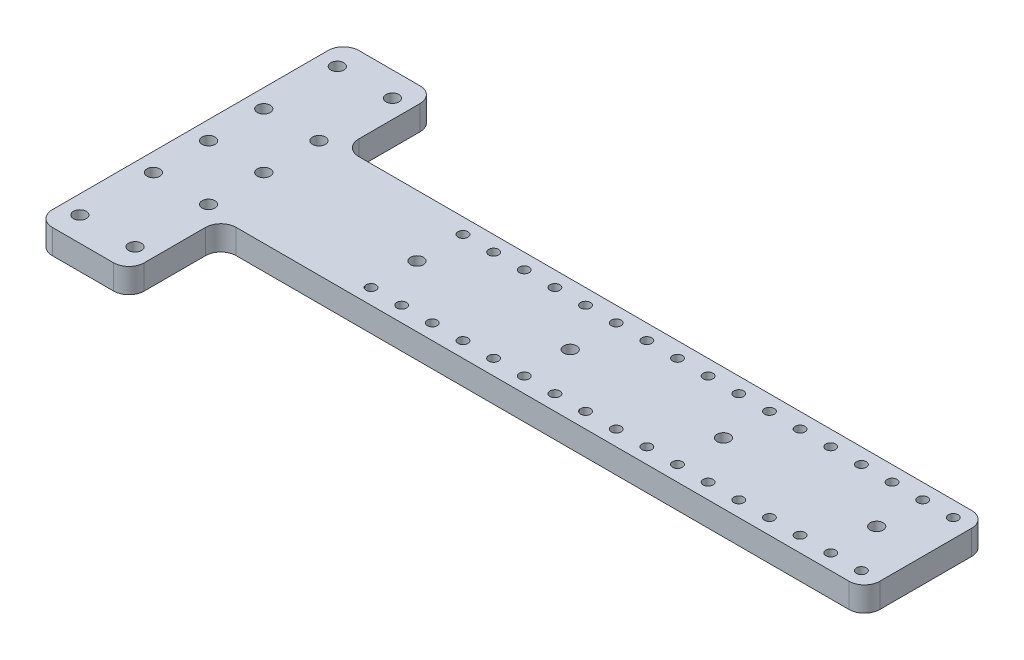
from build123d import *

# Parameters (mm, degrees)
SKETCH1_W           = 30
SKETCH1_H           = 100
SKETCH1_W_2         = 210
SKETCH1_H_2         = 40
BOSS_EXTRUDE1_DEPTH = 8
SKETCH3_R           = 2.1
CUT_EXTRUDE2_DEPTH  = 10
SKETCH2_R           = 2.1
CUT_EXTRUDE3_DEPTH  = 10
SKETCH4_R           = 1.6
CUT_EXTRUDE4_DEPTH  = 10
FILLET1_R           = 5


with BuildPart() as part:
    # Sketch1 → Boss-Extrude1 (new body)
    with BuildSketch(Plane(origin=(0, 0, 0), x_dir=(1, 0, 0), z_dir=(0, 1, 0))):
        Rectangle(SKETCH1_W, SKETCH1_H)
        with Locations((120, 0)):
            Rectangle(SKETCH1_W_2, SKETCH1_H_2)
    extrude(amount=BOSS_EXTRUDE1_DEPTH)

    # Sketch3 → Cut-Extrude2 (cut)
    with BuildSketch(Plane(origin=(0, 8, 0), x_dir=(1, 0, 0), z_dir=(0, 1, 0))):
        with Locations((-9, 0)):
            Circle(SKETCH3_R)
        with Locations((9, 0)):
            Circle(SKETCH3_R)
        with Locations((59, 0)):
            Circle(SKETCH3_R)
        with Locations((109, 0)):
            Circle(SKETCH3_R)
        with Locations((159, 0)):
            Circle(SKETCH3_R)
        with Locations((209, 0)):
            Circle(SKETCH3_R)
    extrude(amount=-CUT_EXTRUDE2_DEPTH, mode=Mode.SUBTRACT)

    # Sketch2 → Cut-Extrude3 (cut)
    with BuildSketch(Plane(origin=(0, 8, 0), x_dir=(1, 0, 0), z_dir=(0, 1, 0))):
        with Locations((-9, -42)):
            Circle(SKETCH2_R)
        with Locations((-9, -18)):
            Circle(SKETCH2_R)
        with Locations((9, -18)):
            Circle(SKETCH2_R)
        with Locations((9, -42)):
            Circle(SKETCH2_R)
        with Locations((9, 42)):
            Circle(SKETCH2_R)
        with Locations((9, 18)):
            Circle(SKETCH2_R)
        with Locations((-9, 18)):
            Circle(SKETCH2_R)
        with Locations((-9, 42)):
            Circle(SKETCH2_R)
    extrude(amount=-CUT_EXTRUDE3_DEPTH, mode=Mode.SUBTRACT)

    # Sketch4 → Cut-Extrude4 (cut)
    with BuildSketch(Plane(origin=(0, 8, 0), x_dir=(1, 0, 0), z_dir=(0, 1, 0))):
        with Locations((59, -15)):
            Circle(SKETCH4_R)
        with Locations((59, 15)):
            Circle(SKETCH4_R)
        with Locations((69, 15)):
            Circle(SKETCH4_R)
        with Locations((69, -15)):
            Circle(SKETCH4_R)
        with Locations((79, 15)):
            Circle(SKETCH4_R)
        with Locations((79, -15)):
            Circle(SKETCH4_R)
        with Locations((89, 15)):
            Circle(SKETCH4_R)
        with Locations((89, -15)):
            Circle(SKETCH4_R)
        with Locations((99, -15)):
            Circle(SKETCH4_R)
        with Locations((99, 15)):
            Circle(SKETCH4_R)
        with Locations((109, -15)):
            Circle(SKETCH4_R)
        with Locations((109, 15)):
            Circle(SKETCH4_R)
        with Locations((119, -15)):
            Circle(SKETCH4_R)
        with Locations((119, 15)):
            Circle(SKETCH4_R)
        with Locations((129, -15)):
            Circle(SKETCH4_R)
        with Locations((129, 15)):
            Circle(SKETCH4_R)
        with Locations((139, -15)):
            Circle(SKETCH4_R)
        with Locations((139, 15)):
            Circle(SKETCH4_R)
        with Locations((149, -15)):
            Circle(SKETCH4_R)
        with Locations((149, 15)):
            Circle(SKETCH4_R)
        with Locations((159, -15)):
            Circle(SKETCH4_R)
        with Locations((159, 15)):
            Circle(SKETCH4_R)
        with Locations((169, -15)):
            Circle(SKETCH4_R)
        with Locations((169, 15)):
            Circle(SKETCH4_R)
        with Locations((179, -15)):
            Circle(SKETCH4_R)
        with Locations((179, 15)):
            Circle(SKETCH4_R)
        with Locations((189, 15)):
            Circle(SKETCH4_R)
        with Locations((189, -15)):
            Circle(SKETCH4_R)
        with Locations((199, 15)):
            Circle(SKETCH4_R)
        with Locations((199, -15)):
            Circle(SKETCH4_R)
        with Locations((209, 15)):
            Circle(SKETCH4_R)
        with Locations((209, -15)):
            Circle(SKETCH4_R)
        with Locations((219, 15)):
            Circle(SKETCH4_R)
        with Locations((219, -15)):
            Circle(SKETCH4_R)
    extrude(amount=-CUT_EXTRUDE4_DEPTH, mode=Mode.SUBTRACT)

    # Fillet1
    fillet1_edges = [part.edges().sort_by_distance(p)[0] for p in [
        (15, 4, -20),
        (225, 4, -20),
        (225, 4, 20),
        (15, 4, 20),
        (15, 4, 50),
        (-15, 4, 50),
        (-15, 4, -50),
        (15, 4, -50),
    ]]
    fillet(fillet1_edges, radius=FILLET1_R)


solid = part.part
